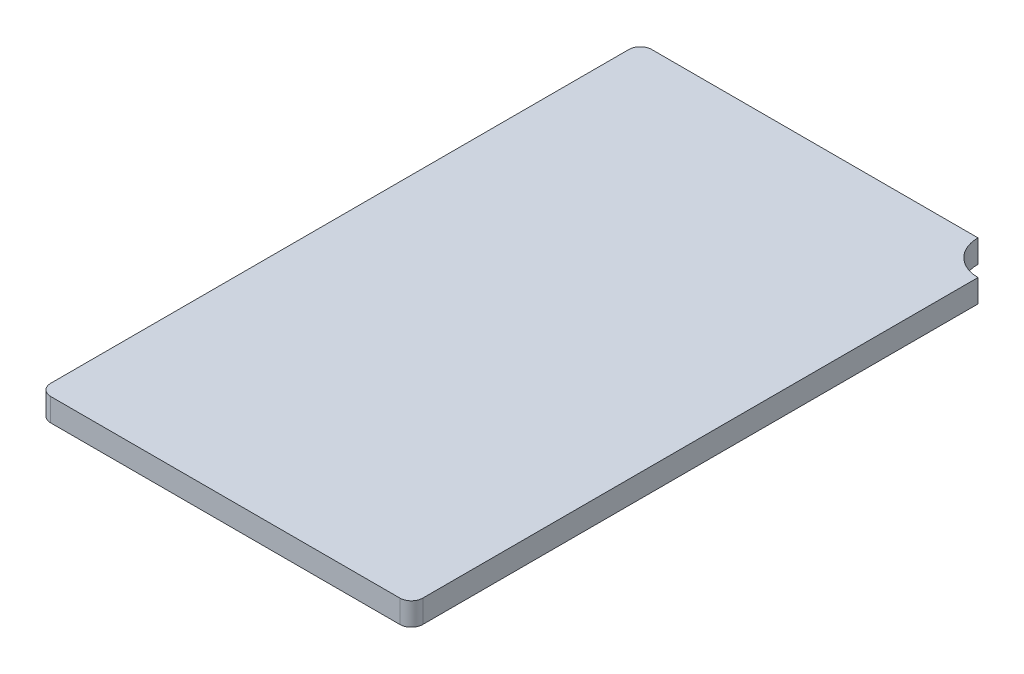
from build123d import *

# Parameters (mm, degrees)
SKETCH1_W           = 3.25
SKETCH1_H           = 5.25
BOSS_EXTRUDE1_DEPTH = 0.2
SKETCH2_R           = 0.3
CUT_EXTRUDE1_DEPTH  = 1.2
FILLET1_R           = 0.1


with BuildPart() as part:
    # Sketch1 → Boss-Extrude1 (new body)
    with BuildSketch(Plane(origin=(0, 0, 0), x_dir=(1, 0, 0), z_dir=(0, 1, 0))):
        Rectangle(SKETCH1_W, SKETCH1_H)
    extrude(amount=BOSS_EXTRUDE1_DEPTH)

    # Sketch2 → Cut-Extrude1 (cut, through all)
    with BuildSketch(Plane(origin=(0, 0.2, 0), x_dir=(1, 0, 0), z_dir=(0, 1, 0))):
        with Locations((1.625, 2.625)):
            Circle(SKETCH2_R)
    extrude(amount=-CUT_EXTRUDE1_DEPTH, mode=Mode.SUBTRACT)

    # Fillet1
    fillet1_edges = [part.edges().sort_by_distance(p)[0] for p in [
        (1.625, 0.1, 2.625),
        (-1.625, 0.1, 2.625),
        (-1.625, 0.1, -2.625),
    ]]
    fillet(fillet1_edges, radius=FILLET1_R)


solid = part.part
